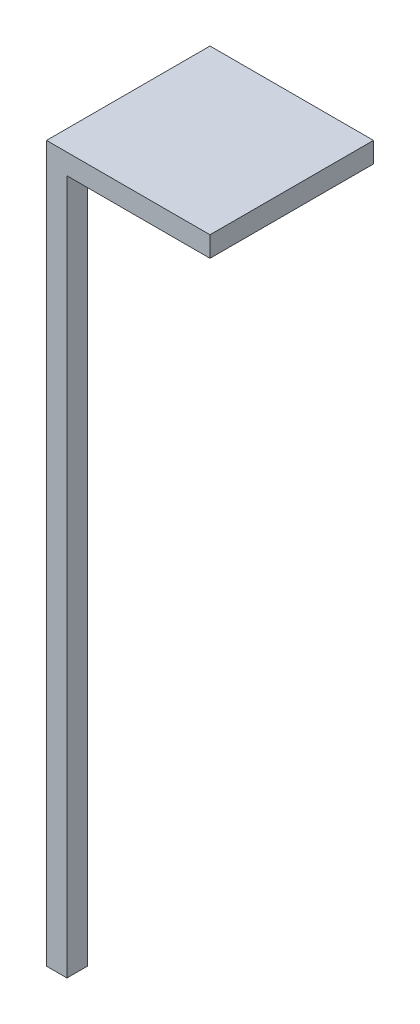
from build123d import *

# Parameters (mm, degrees)
ESQUISSE1_W      = 10
ESQUISSE1_H      = 10
EXTRUSION1_DEPTH = 340
ESQUISSE2_W      = 80
ESQUISSE2_H      = 80
EXTRUSION2_DEPTH = 10


with BuildPart() as part:
    # Esquisse1 → Extrusion1 (new body)
    with BuildSketch(Plane(origin=(0, 0, 0), x_dir=(1, 0, 0), z_dir=(0, 1, 0))):
        with Locations((5, 5)):
            Rectangle(ESQUISSE1_W, ESQUISSE1_H)
    extrude(amount=EXTRUSION1_DEPTH)

    # Esquisse2 → Extrusion2 (add)
    with BuildSketch(Plane(origin=(0, 340, 0), x_dir=(1, 0, 0), z_dir=(0, 1, 0))):
        with Locations((40, 40)):
            Rectangle(ESQUISSE2_W, ESQUISSE2_H)
    extrude(amount=EXTRUSION2_DEPTH)


solid = part.part
